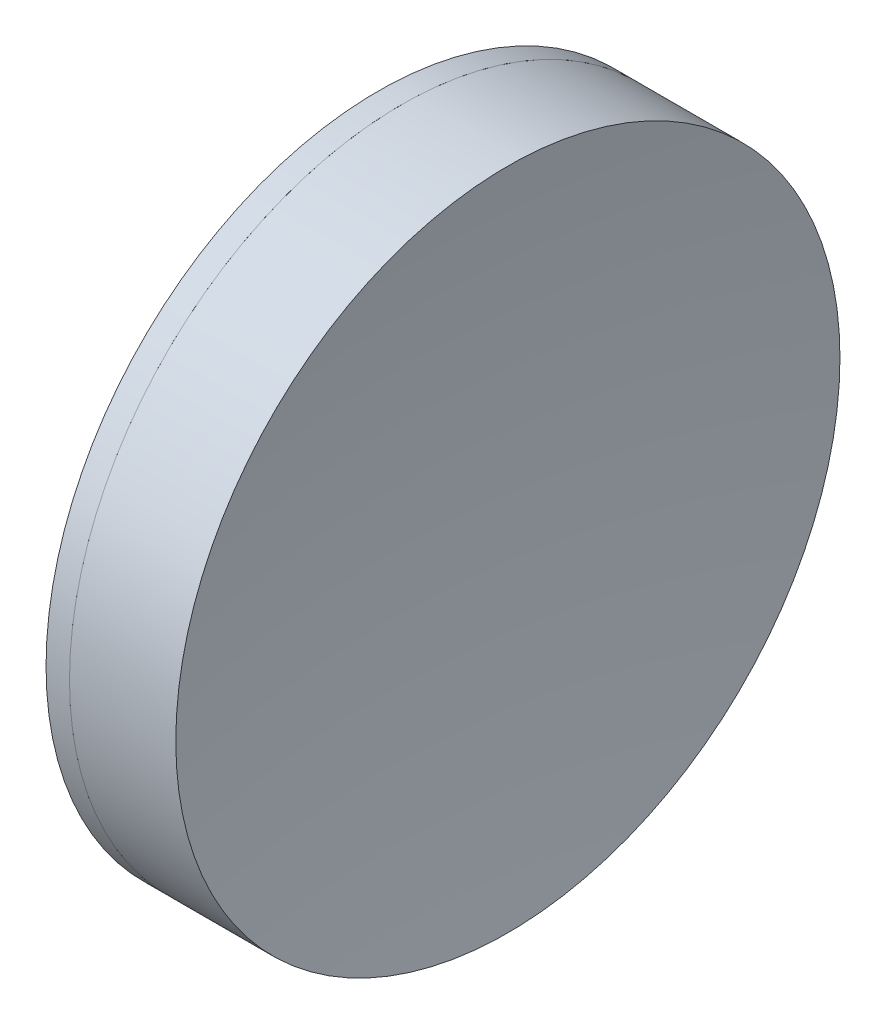
from build123d import *


with BuildPart() as part:
    # 草图1 one side → 旋转1 (revolve)
    with BuildSketch(Plane(origin=(0, 0, 0), x_dir=(1, 0, 0), z_dir=(0, 1, 0)), mode=Mode.PRIVATE) as revolve_1_sk:
        with BuildLine():
            ThreePointArc((184.539741179, 25.4), (181.671249825, 12.84370473), (180.707900269, 0))
            Line((180.707900269, 0), (189.507900269, 0))
            ThreePointArc((189.507900269, 0), (188.711174013, 12.79880957), (186.333297044, 25.4))
            Line((186.333297044, 25.4), (184.539741179, 25.4))
        make_face()
    revolve(revolve_1_sk.sketch.rotate(Axis((-0.816062176, 0, 0), (1, 0, 0)), 180), axis=Axis((-0.816062176, 0, 0), (1, 0, 0)))  # turned: the seam where the file's is


with BuildPart() as body_2:
    # 草图2 one side → 旋转2 (revolve)
    with BuildSketch(Plane(origin=(0, 0, 0), x_dir=(1, 0, 0), z_dir=(0, 1, 0))):
        with BuildLine():
            Line((194.463139362, 25.4), (186.333297044, 25.4))
            ThreePointArc((186.333297044, 25.4), (188.711174013, 12.79880957), (189.507900269, 0))
            Line((189.507900269, 0), (192.507900269, 0))
            ThreePointArc((192.507900269, 0), (192.997432027, 12.737571981), (194.463139362, 25.4))
        make_face()
    revolve(axis=Axis((-0.551919993, 0, 0), (1, 0, 0)))


solid = Compound([part.part, body_2.part])
